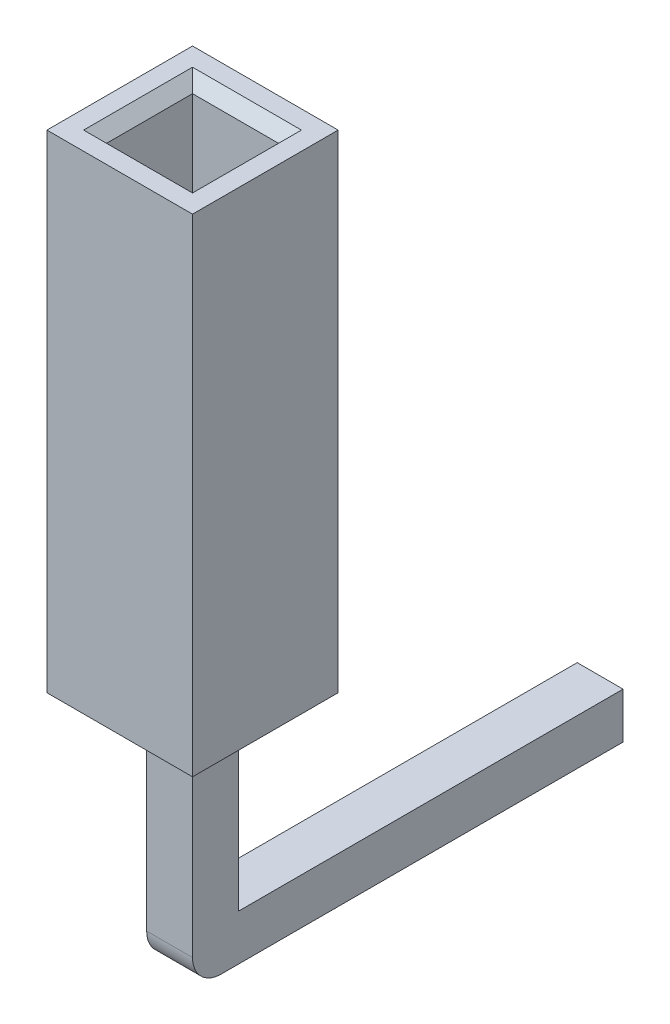
from build123d import *

# Parameters (mm, degrees)
SKETCH_1_W      = 2.54
SKETCH_1_H      = 2.54
SKETCH_1_W_2    = 1.5
SKETCH_1_H_2    = 1.5
EXTRUDE_1_DEPTH = 8.5
SKETCH_2_2_W    = 0.8
SKETCH_2_2_H    = 0.8
CHAMFER_1_SIZE  = 0.2
CHAMFER_3_SIZE  = 0.2
FILLET_2_R      = 0.5


with BuildPart() as part:
    # Эскиз1 → Бобышка-Вытянуть1 (new body)
    with BuildSketch(Plane(origin=(0, 0, 0), x_dir=(1, 0, 0), z_dir=(0, 1, 0))):
        with Locations((1.27, 1.27)):
            Rectangle(SKETCH_1_W, SKETCH_1_H)
        with Locations((1.27, 1.27)):
            Rectangle(SKETCH_1_W_2, SKETCH_1_H_2, mode=Mode.SUBTRACT)
    extrude(amount=EXTRUDE_1_DEPTH)

    # Фаска1
    chamfer_1_edges = [part.edges().sort_by_distance(p)[0] for p in [
        (1.27, 8.5, -2.02),
        (2.02, 8.5, -1.27),
        (1.27, 8.5, -0.52),
        (0.52, 8.5, -1.27),
    ]]
    chamfer(chamfer_1_edges, length=CHAMFER_1_SIZE)


with BuildPart() as body_2:
    # По траектории2: sweep along a path in Эскиз4
    with BuildLine(Plane(origin=(1.27, 0, 0), x_dir=(0, 0, -1), z_dir=(1, 0, 0))) as sweep_2_path:
        Line((1.27, 0), (1.27, -3.7))
        Line((1.27, -3.7), (8.58, -3.7))
    # Эскиз2<2> → По траектории2 (sweep)
    with BuildSketch(Plane.XZ):
        with Locations((1.27, -1.27)):
            Rectangle(SKETCH_2_2_W, SKETCH_2_2_H)
    sweep(path=sweep_2_path.line, transition=Transition.RIGHT)

    # Фаска3
    chamfer_3_edges = [body_2.edges().sort_by_distance(p)[0] for p in [
        (1.27, -3.3, -8.58),
        (0.87, -3.7, -8.58),
        (1.27, -4.1, -8.58),
        (1.67, -3.7, -8.58),
    ]]
    chamfer(chamfer_3_edges, length=CHAMFER_3_SIZE)

    # Скругление2
    fillet_2_edges = [body_2.edges().sort_by_distance(p)[0] for p in [
        (1.27, -4.1, -0.87),
    ]]
    fillet(fillet_2_edges, radius=FILLET_2_R)


solid = Compound([part.part, body_2.part])
